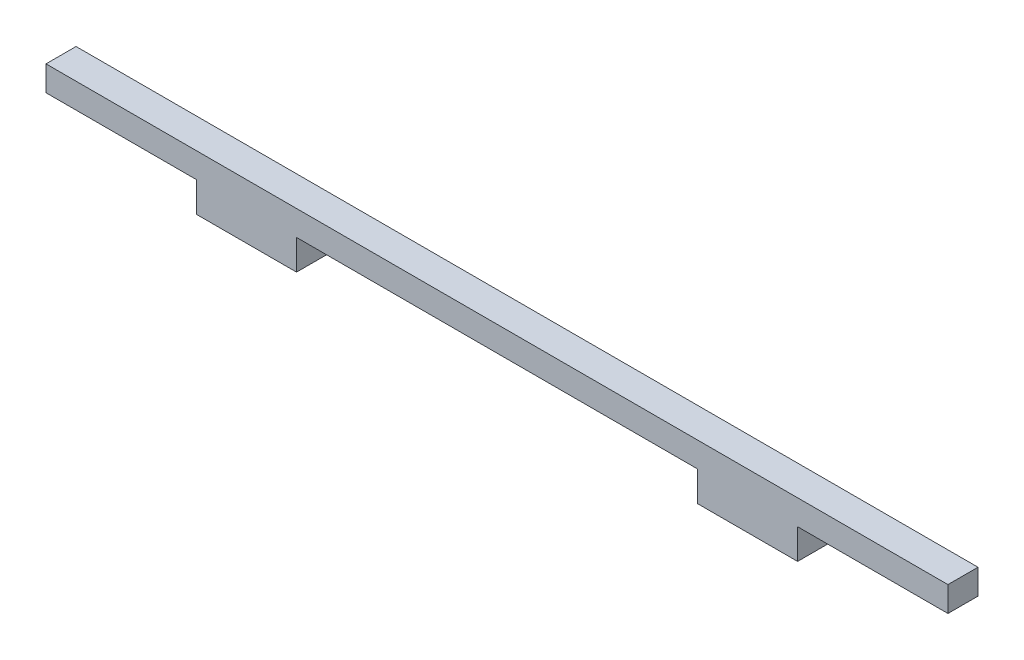
from build123d import *

# Parameters (mm, degrees)
BOSS_EXTRUDE1_DEPTH = 3


with BuildPart() as part:
    # Sketch1 → Boss-Extrude1 (new body)
    with BuildSketch(Plane.XY):
        Polygon((-45, 0), (45, 0), (45, -2.5), (30, -2.5), (30, -5.5), (20, -5.5), (20, -2.5), (-20, -2.5), (-20, -5.5), (-30, -5.5), (-30, -2.5), (-45, -2.5), align=None)
    extrude(amount=BOSS_EXTRUDE1_DEPTH)


solid = part.part
